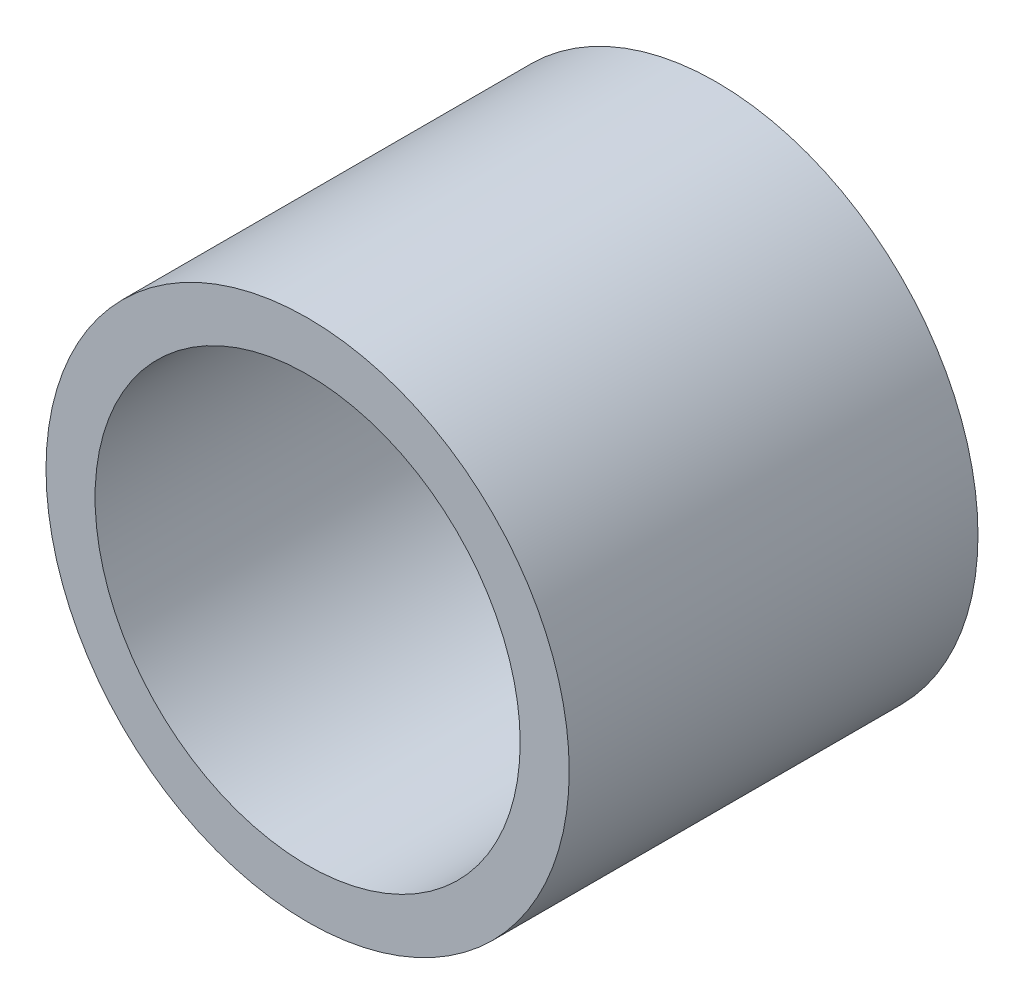
from build123d import *

# Parameters (mm, degrees)
SKETCH_1_R      = 16
SKETCH_1_R_2    = 13
EXTRUDE_1_DEPTH = 25


with BuildPart() as part:
    # 草图1 → 凸台-拉伸1 (new body)
    with BuildSketch(Plane.XY):
        Circle(SKETCH_1_R)
        Circle(SKETCH_1_R_2, mode=Mode.SUBTRACT)
    extrude(amount=EXTRUDE_1_DEPTH)


solid = part.part
